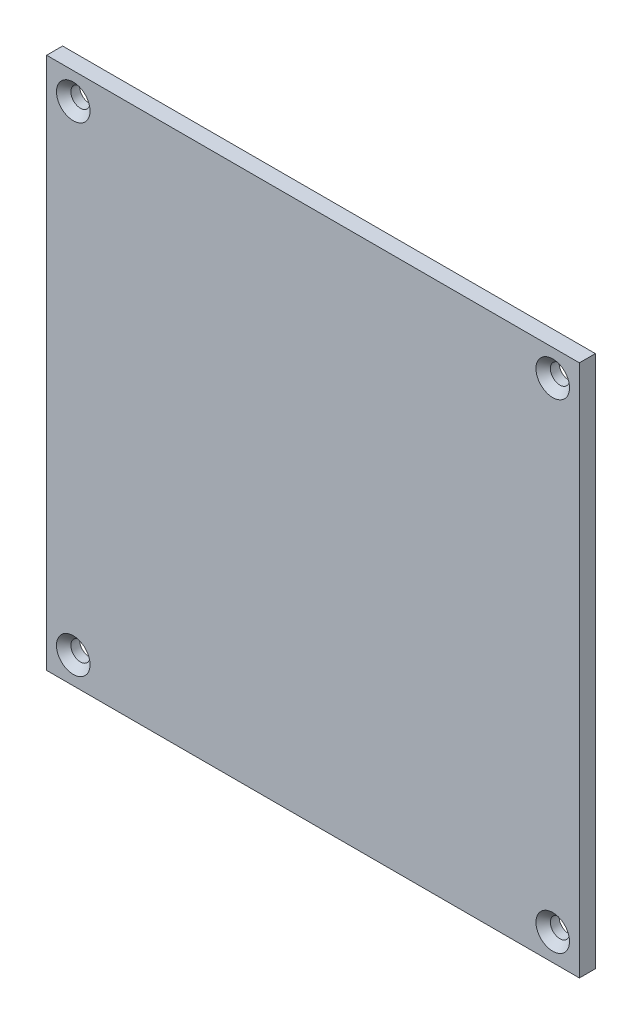
from build123d import *

# Parameters (mm, degrees)
ESQUISSE1_W                                 = 100
ESQUISSE1_H                                 = 100
BOSS_EXTRU_1_DEPTH                          = 3
FRAISAGE_POUR_VIS_T_TE_FRAIS_E_M31_AT_COUNT = 2
FRAISAGE_POUR_VIS_T_TE_FRAIS_E_M31_AT_PITCH = 90
FRAISAGE_POUR_VIS_T_TE_FRAIS_E_M31_2_COUNT  = 2
FRAISAGE_POUR_VIS_T_TE_FRAIS_E_M31_2_PITCH  = 127.279220614
FRAISAGE_POUR_VIS_T_TE_FRAIS_E_M31_3_COUNT  = 2
FRAISAGE_POUR_VIS_T_TE_FRAIS_E_M31_3_PITCH  = 90


with BuildPart() as part:
    # Esquisse1 → Boss.-Extru.1 (new body)
    with BuildSketch(Plane.XY):
        with Locations((50, 50)):
            Rectangle(ESQUISSE1_W, ESQUISSE1_H)
    extrude(amount=BOSS_EXTRU_1_DEPTH)

    # Esquisse3 → Fraisage pour vis à tête fraisée M31 (revolve, cut)
    with BuildSketch(Plane(origin=(5, 95, 3), x_dir=(0, -1, 0), z_dir=(1, 0, 0))):
        Polygon((0, 0), (0, 3), (1.8, 3), (1.8, 1.35), (3.15, 0), align=None)
    fraisage_pour_vis_t_te_frais_e_m31 = revolve(axis=Axis((5, 95, 9.35), (0, 0, -1)), mode=Mode.SUBTRACT)

    # Fraisage pour vis à tête fraisée M31 at: Fraisage pour vis à tête fraisée M31 ×2
    with Locations(*[(i * FRAISAGE_POUR_VIS_T_TE_FRAIS_E_M31_AT_PITCH, 0, 0) for i in range(1, FRAISAGE_POUR_VIS_T_TE_FRAIS_E_M31_AT_COUNT)]):
        add(fraisage_pour_vis_t_te_frais_e_m31, mode=Mode.SUBTRACT)

    # Fraisage pour vis _ t_te frais_e M31 2: Fraisage pour vis à tête fraisée M31 ×2
    with Locations(*[Vector(0.707106781, -0.707106781, 0) * (i * FRAISAGE_POUR_VIS_T_TE_FRAIS_E_M31_2_PITCH) for i in range(1, FRAISAGE_POUR_VIS_T_TE_FRAIS_E_M31_2_COUNT)]):
        add(fraisage_pour_vis_t_te_frais_e_m31, mode=Mode.SUBTRACT)

    # Fraisage pour vis _ t_te frais_e M31 3: Fraisage pour vis à tête fraisée M31 ×2
    with Locations(*[(0, -i * FRAISAGE_POUR_VIS_T_TE_FRAIS_E_M31_3_PITCH, 0) for i in range(1, FRAISAGE_POUR_VIS_T_TE_FRAIS_E_M31_3_COUNT)]):
        add(fraisage_pour_vis_t_te_frais_e_m31, mode=Mode.SUBTRACT)


solid = part.part
